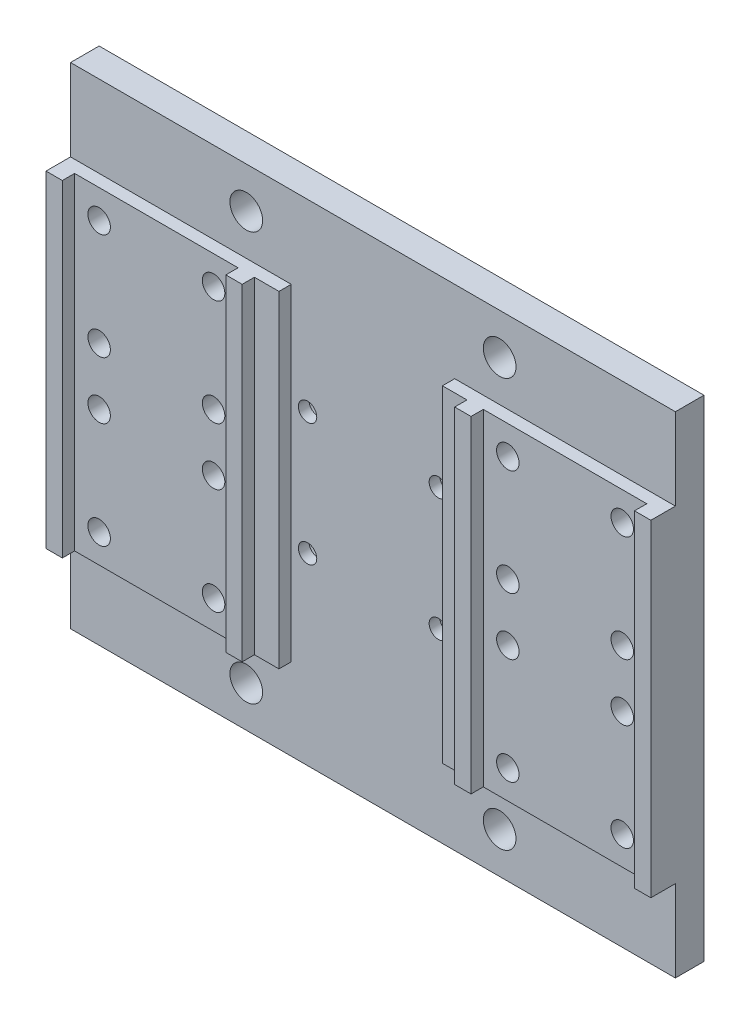
from build123d import *

# Parameters (mm, degrees)
ESQUISSE1_W                                        = 148
ESQUISSE1_H                                        = 120
ESQUISSE1_R                                        = 2.5
ESQUISSE1_R_2                                      = 2
EXTRUSION1_DEPTH                                   = 4
ESQUISSE4_W                                        = 54
ESQUISSE4_H                                        = 80
BOSS_EXTRU_1_DEPTH                                 = 3
ESQUISSE6_W                                        = 148
ESQUISSE6_H                                        = 120
BOSS_EXTRU_2_DEPTH                                 = 3
CHAMBRAGE_POUR_VIS_T_TE_HEXAGONALE_M41_D           = 4.5
CHAMBRAGE_POUR_VIS_T_TE_HEXAGONALE_M41_CBORE_D     = 10
CHAMBRAGE_POUR_VIS_T_TE_HEXAGONALE_M41_CBORE_DEPTH = 4.4
CHAMBRAGE_POUR_VIS_T_TE_HEXAGONALE_M51_D           = 5.5
CHAMBRAGE_POUR_VIS_T_TE_HEXAGONALE_M51_CBORE_D     = 11
CHAMBRAGE_POUR_VIS_T_TE_HEXAGONALE_M51_CBORE_DEPTH = 5.4
ESQUISSE11_W                                       = 4
ESQUISSE11_H                                       = 80
BOSS_EXTRU_3_DEPTH                                 = 3
ESQUISSE3_R                                        = 4
ENL_V_MAT_EXTRU_2_DEPTH                            = 8


with BuildPart() as part:
    # Esquisse1 → Extrusion1 (new body)
    with BuildSketch(Plane.XY):
        with Locations((0, 6.392373056)):
            Rectangle(ESQUISSE1_W, ESQUISSE1_H)
        with Locations((-64, -0.607626944)):
            Circle(ESQUISSE1_R, mode=Mode.SUBTRACT)
        with Locations((-36, -0.607626944)):
            Circle(ESQUISSE1_R, mode=Mode.SUBTRACT)
        with Locations((-64, -26.607626944)):
            Circle(ESQUISSE1_R, mode=Mode.SUBTRACT)
        with Locations((-36, -26.607626944)):
            Circle(ESQUISSE1_R, mode=Mode.SUBTRACT)
        with Locations((36, -0.607626944)):
            Circle(ESQUISSE1_R, mode=Mode.SUBTRACT)
        with Locations((64, -0.607626944)):
            Circle(ESQUISSE1_R, mode=Mode.SUBTRACT)
        with Locations((36, -26.607626944)):
            Circle(ESQUISSE1_R, mode=Mode.SUBTRACT)
        with Locations((64, -26.607626944)):
            Circle(ESQUISSE1_R, mode=Mode.SUBTRACT)
        with Locations((64, 39.392373056)):
            Circle(ESQUISSE1_R, mode=Mode.SUBTRACT)
        with Locations((36, 39.392373056)):
            Circle(ESQUISSE1_R, mode=Mode.SUBTRACT)
        with Locations((16, 21.392373056)):
            Circle(ESQUISSE1_R_2, mode=Mode.SUBTRACT)
        with Locations((16, -8.607626944)):
            Circle(ESQUISSE1_R_2, mode=Mode.SUBTRACT)
        with Locations((-16, 21.392373056)):
            Circle(ESQUISSE1_R_2, mode=Mode.SUBTRACT)
        with Locations((-16, -8.607626944)):
            Circle(ESQUISSE1_R_2, mode=Mode.SUBTRACT)
        with Locations((64, 13.392373056)):
            Circle(ESQUISSE1_R, mode=Mode.SUBTRACT)
        with Locations((36, 13.392373056)):
            Circle(ESQUISSE1_R, mode=Mode.SUBTRACT)
        with Locations((-36, 39.392373056)):
            Circle(ESQUISSE1_R, mode=Mode.SUBTRACT)
        with Locations((-64, 39.392373056)):
            Circle(ESQUISSE1_R, mode=Mode.SUBTRACT)
        with Locations((-36, 13.392373056)):
            Circle(ESQUISSE1_R, mode=Mode.SUBTRACT)
        with Locations((-64, 13.392373056)):
            Circle(ESQUISSE1_R, mode=Mode.SUBTRACT)
    extrude(amount=EXTRUSION1_DEPTH)

    # Esquisse4 → Boss.-Extru.1 (add)
    with BuildSketch(Plane.XY.offset(4)):
        with Locations((-47, 6.392373056)):
            Rectangle(ESQUISSE4_W, ESQUISSE4_H)
        with Locations((47, 6.392373056)):
            Rectangle(ESQUISSE4_W, ESQUISSE4_H)
    extrude(amount=BOSS_EXTRU_1_DEPTH)

    # Esquisse6 → Boss.-Extru.2 (add)
    with BuildSketch(Plane(origin=(0, 0, 0), x_dir=(-1, 0, 0), z_dir=(0, 0, -1))):
        with Locations((0, 6.392373056)):
            Rectangle(ESQUISSE6_W, ESQUISSE6_H)
    extrude(amount=BOSS_EXTRU_2_DEPTH)

    # Chambrage pour vis à tête hexagonale M41 (through all)
    with Locations(Plane(origin=(0, 0, -3), x_dir=(-1, 0, 0), z_dir=(0, 0, -1))):
        with Locations((-16, 21.392373056), (16, 21.392373056), (16, -8.607626944), (-16, -8.607626944)):
            CounterBoreHole(CHAMBRAGE_POUR_VIS_T_TE_HEXAGONALE_M41_D / 2, CHAMBRAGE_POUR_VIS_T_TE_HEXAGONALE_M41_CBORE_D / 2, CHAMBRAGE_POUR_VIS_T_TE_HEXAGONALE_M41_CBORE_DEPTH)

    # Chambrage pour vis à tête hexagonale M51 (through all)
    with Locations(Plane(origin=(0, 0, -3), x_dir=(-1, 0, 0), z_dir=(0, 0, -1))):
        with Locations((-64, -0.607626944), (-36, -0.607626944), (-36, -26.607626944), (-64, -26.607626944), (36, -0.607626944), (64, -0.607626944), (64, -26.607626944), (36, -26.607626944), (64, 39.392373056), (64, 13.392373056), (36, 39.392373056), (36, 13.392373056), (-36, 39.392373056), (-64, 39.392373056), (-64, 13.392373056), (-36, 13.392373056)):
            CounterBoreHole(CHAMBRAGE_POUR_VIS_T_TE_HEXAGONALE_M51_D / 2, CHAMBRAGE_POUR_VIS_T_TE_HEXAGONALE_M51_CBORE_D / 2, CHAMBRAGE_POUR_VIS_T_TE_HEXAGONALE_M51_CBORE_DEPTH)

    # Esquisse11 → Boss.-Extru.3 (add)
    with BuildSketch(Plane.XY.offset(7)):
        with Locations((-28, 6.392373056)):
            Rectangle(ESQUISSE11_W, ESQUISSE11_H)
        with Locations((28, 6.392373056)):
            Rectangle(ESQUISSE11_W, ESQUISSE11_H)
        with Locations((-72, 6.392373056)):
            Rectangle(ESQUISSE11_W, ESQUISSE11_H)
        with Locations((72, 6.392373056)):
            Rectangle(ESQUISSE11_W, ESQUISSE11_H)
    extrude(amount=BOSS_EXTRU_3_DEPTH)

    # Esquisse3 → Enlèv. mat.-Extru.2 (cut, through all)
    with BuildSketch(Plane.XY.offset(4)):
        with Locations((-31, 56.392373056)):
            Circle(ESQUISSE3_R)
        with Locations((31, 56.392373056)):
            Circle(ESQUISSE3_R)
        with Locations((-31, -43.607626944)):
            Circle(ESQUISSE3_R)
        with Locations((31, -43.607626944)):
            Circle(ESQUISSE3_R)
    extrude(amount=-ENL_V_MAT_EXTRU_2_DEPTH, mode=Mode.SUBTRACT)


solid = part.part
